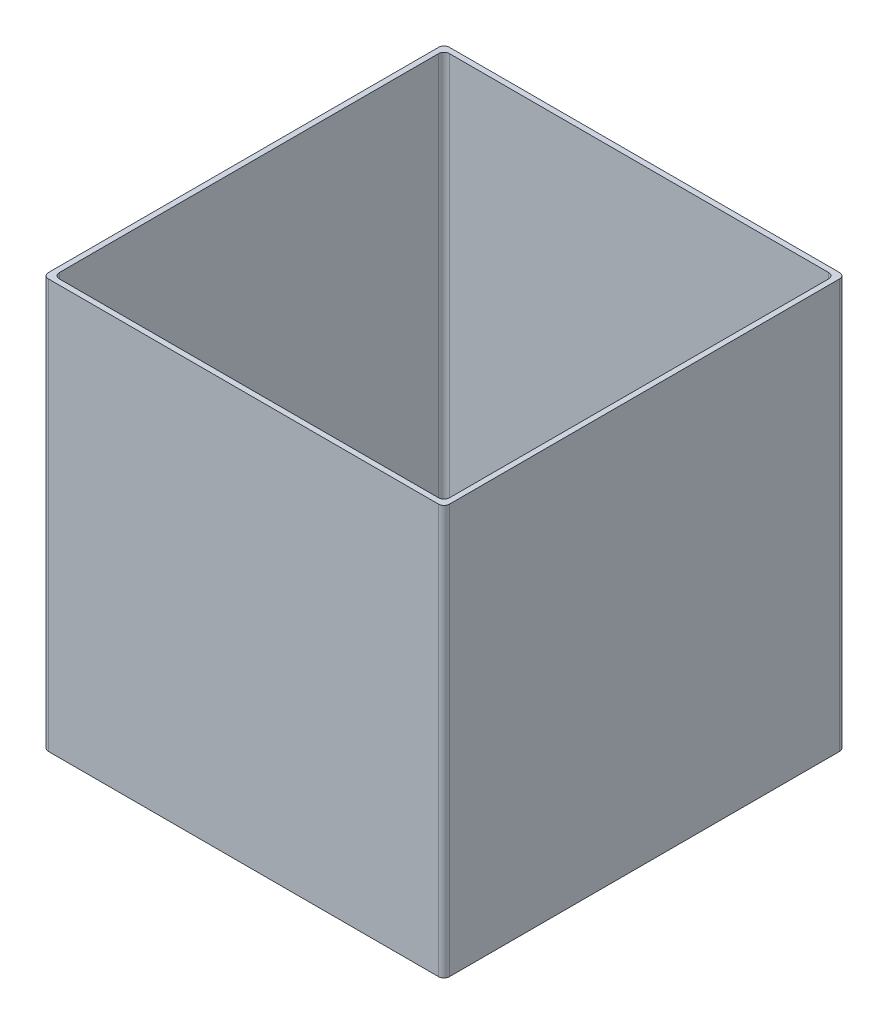
from build123d import *

# Parameters (mm, degrees)
EXTRUDE_1_DEPTH = 150


with BuildPart() as part:
    # Эскиз1 → Бобышка-Вытянуть1 (new body)
    with BuildSketch(Plane(origin=(0, 0, 0), x_dir=(1, 0, 0), z_dir=(0, 1, 0))):
        with BuildLine():
            Line((2, 0), (145, 0))
            ThreePointArc((145, 0), (146.414213562, 0.585786438), (147, 2))
            Line((147, 2), (147, 145))
            ThreePointArc((147, 145), (146.414213562, 146.414213562), (145, 147))
            Line((145, 147), (2, 147))
            ThreePointArc((2, 147), (0.585786438, 146.414213562), (0, 145))
            Line((0, 145), (0, 2))
            ThreePointArc((0, 2), (0.585786438, 0.585786438), (2, 0))
        make_face()
        with BuildLine():
            Line((4, 145), (143, 145))
            ThreePointArc((143, 145), (144.414213562, 144.414213562), (145, 143))
            Line((145, 143), (145, 4))
            ThreePointArc((145, 4), (144.414213562, 2.585786438), (143, 2))
            Line((143, 2), (4, 2))
            ThreePointArc((4, 2), (2.585786438, 2.585786438), (2, 4))
            Line((2, 4), (2, 143))
            ThreePointArc((2, 143), (2.585786438, 144.414213562), (4, 145))
        make_face(mode=Mode.SUBTRACT)
    extrude(amount=EXTRUDE_1_DEPTH)


solid = part.part
